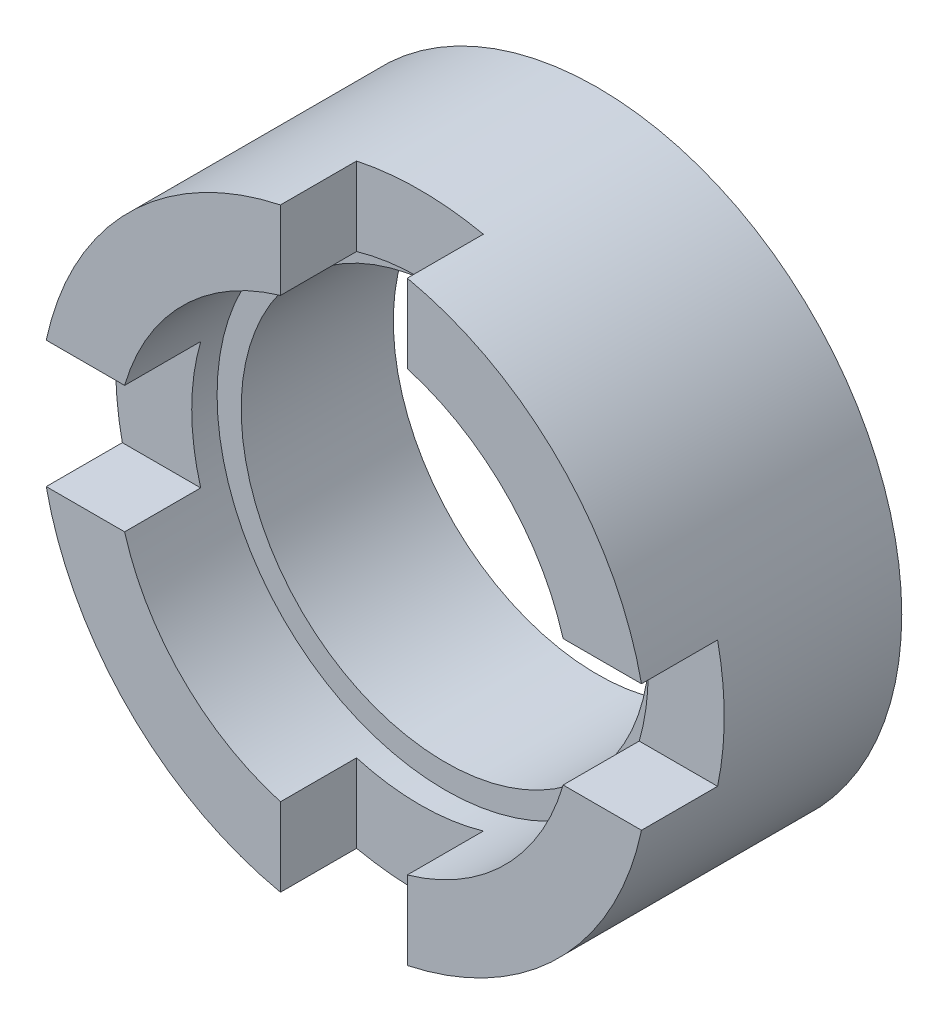
from build123d import *

# Parameters (mm, degrees)
SKETCH_1_R          = 12
SKETCH_1_R_2        = 8.05
EXTRUDE_1_DEPTH     = 10
CUT_EXTRUDE_1_DEPTH = 3
SKETCH_4_R          = 9
CUT_EXTRUDE_2_DEPTH = 4


with BuildPart() as part:
    # 草图1 → 凸台-拉伸1 (new body)
    with BuildSketch(Plane.XY):
        Circle(SKETCH_1_R)
        Circle(SKETCH_1_R_2, mode=Mode.SUBTRACT)
    extrude(amount=EXTRUDE_1_DEPTH)

    # 草图3 → 切除-拉伸1 (cut)
    with BuildSketch(Plane.XY.offset(10)):
        Polygon((-16.5, 2.5), (-2.5, 2.5), (-2.5, 16.5), (2.5, 16.5), (2.5, 2.5), (16.5, 2.5), (16.5, -2.5), (2.5, -2.5), (2.5, -16.5), (-2.5, -16.5), (-2.5, -2.5), (-16.5, -2.5), align=None)
    extrude(amount=-CUT_EXTRUDE_1_DEPTH, mode=Mode.SUBTRACT)

    # 草图4 → 切除-拉伸2 (cut)
    with BuildSketch(Plane.XY.offset(10)):
        Circle(SKETCH_4_R)
    extrude(amount=-CUT_EXTRUDE_2_DEPTH, mode=Mode.SUBTRACT)


solid = part.part
